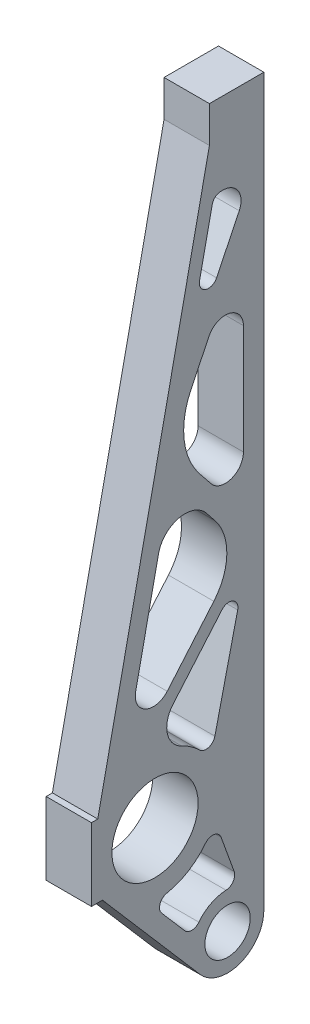
from build123d import *

# Parameters (mm, degrees)
SKETCH1_R                       = 15.08125
SKETCH1_R_2                     = 7.9375
BOSS_EXTRUDE1_DEPTH             = 7.9375
TAP_DRILL_FOR_1_4_28_TAP1_D     = 5.4102
TAP_DRILL_FOR_1_4_28_TAP1_DEPTH = 14.249611939
TAP_DRILL_FOR_1_4_28_TAP1_TIP   = 1.625388061


with BuildPart() as part:
    # Sketch1 → Boss-Extrude1 (new body, symmetric)
    with BuildSketch(Plane(origin=(0, 0, 0), x_dir=(0, 0, -1), z_dir=(1, 0, 0))):
        with BuildLine():
            ThreePointArc((477.273006468, 55.573710947), (477.957555138, 54.643144528), (478.689532564, 53.74940531))
            Line((478.689532564, 53.74940531), (511.29915841, 15.980017214))
            ThreePointArc((511.29915841, 15.980017214), (525.339576994, 12.376406632), (533.611992871, 24.279620434))
            Line((533.611992871, 24.279620434), (533.611992871, 252.869620434))
            ThreePointArc((533.611992871, 252.869620434), (533.621992871, 252.879620434), (533.611992871, 252.889620434))
            Line((533.611992871, 252.889620434), (533.611992871, 278.279620434))
            Line((533.611992871, 278.279620434), (514.561992871, 278.279620434))
            Line((514.561992871, 278.279620434), (514.561992871, 265.579620434))
            Line((514.561992871, 265.579620434), (475.482925659, 80.973710947))
            Line((475.482925659, 80.973710947), (473.286992871, 80.973710947))
            Line((473.286992871, 80.973710947), (473.286992871, 55.573710947))
            Line((473.286992871, 55.573710947), (477.273006468, 55.573710947))
        make_face()
        with Locations((495.511992871, 68.273710947)):
            Circle(SKETCH1_R, mode=Mode.SUBTRACT)
        with BuildLine():
            Line((513.492352541, 154.682917565), (516.491551882, 150.932886553))
            ThreePointArc((516.491551882, 150.932886553), (520.662032348, 138.733869971), (516.108721588, 126.672515404))
            Line((516.108721588, 126.672515404), (499.792202262, 107.541452006))
            ThreePointArc((499.792202262, 107.541452006), (492.156570852, 105.964813857), (488.748431965, 112.977177526))
            Line((488.748431965, 112.977177526), (496.735281949, 150.706320271))
            ThreePointArc((496.735281949, 150.706320271), (503.854492534, 158.001314948), (513.492352541, 154.682917565))
        make_face(mode=Mode.SUBTRACT)
        with BuildLine():
            Line((505.940679161, 31.90308853), (497.871284255, 41.249289229))
            ThreePointArc((497.871284255, 41.249289229), (497.275971755, 44.367979343), (499.679180371, 46.442880148))
            ThreePointArc((499.679180371, 46.442880148), (507.170500261, 49.352034741), (513.137493678, 54.73516057))
            ThreePointArc((513.137493678, 54.73516057), (516.142098705, 55.938560413), (518.64094789, 53.8814811))
            Line((518.64094789, 53.8814811), (523.222631148, 41.220667502))
            ThreePointArc((523.222631148, 41.220667502), (522.874411989, 38.372433477), (520.372083072, 36.968138764))
            ThreePointArc((520.372083072, 36.968138764), (515.06938347, 35.555874927), (510.857508795, 32.038315555))
            ThreePointArc((510.857508795, 32.038315555), (508.431176446, 30.804189453), (505.940679161, 31.90308853))
        make_face(mode=Mode.SUBTRACT)
        with Locations((520.911992871, 24.279620434)):
            Circle(SKETCH1_R_2, mode=Mode.SUBTRACT)
        with BuildLine():
            ThreePointArc((518.944357913, 122.658172896), (522.790818804, 123.432213046), (524.452355406, 119.877822007))
            Line((524.452355406, 119.877822007), (516.472291206, 85.606211423))
            ThreePointArc((516.472291206, 85.606211423), (514.260132633, 83.275664888), (511.146510795, 84.069674807))
            ThreePointArc((511.146510795, 84.069674807), (508.195718311, 86.524018724), (504.866661886, 88.434087744))
            ThreePointArc((504.866661886, 88.434087744), (499.826228678, 94.721972649), (501.785115668, 102.539019742))
            Line((501.785115668, 102.539019742), (518.944357913, 122.658172896))
        make_face(mode=Mode.SUBTRACT)
        with BuildLine():
            ThreePointArc((526.468242871, 166.731606566), (522.219734771, 160.739425678), (515.159193487, 162.76545866))
            Line((515.159193487, 162.76545866), (511.105468766, 167.834009193))
            ThreePointArc((511.105468766, 167.834009193), (505.69956043, 180.870864765), (508.086772693, 194.780741319))
            Line((508.086772693, 194.780741319), (514.404519469, 207.809941801))
            ThreePointArc((514.404519469, 207.809941801), (521.5395726, 211.228293635), (526.468242871, 205.039406675))
            Line((526.468242871, 205.039406675), (526.468242871, 166.731606566))
        make_face(mode=Mode.SUBTRACT)
        with BuildLine():
            ThreePointArc((515.536548916, 247.187161956), (516.643598283, 248.996229375), (518.642714422, 249.704620434))
            Line((518.642714422, 249.704620434), (519.289846204, 249.704620434))
            ThreePointArc((519.289846204, 249.704620434), (524.671082031, 246.725792482), (525.003569607, 240.584085308))
            Line((525.003569607, 240.584085308), (517.071165151, 224.224947846))
            ThreePointArc((517.071165151, 224.224947846), (513.18532078, 222.606581), (511.108137945, 226.26775693))
            Line((511.108137945, 226.26775693), (515.536548916, 247.187161956))
        make_face(mode=Mode.SUBTRACT)
    extrude(amount=BOSS_EXTRUDE1_DEPTH, both=True)

    # Tap Drill for 1/4-28 Tap1
    with Locations(Plane(origin=(0, 271.929620434, -533.611992871), x_dir=(-1, 0, 0), z_dir=(0, 0, -1))):
        with Locations((0, 0), (0, -12.7)):
            Hole(TAP_DRILL_FOR_1_4_28_TAP1_D / 2, depth=TAP_DRILL_FOR_1_4_28_TAP1_DEPTH)
            with Locations((0, 0, -(TAP_DRILL_FOR_1_4_28_TAP1_DEPTH + TAP_DRILL_FOR_1_4_28_TAP1_TIP / 2))):  # 118° drill point
                Cone(0, TAP_DRILL_FOR_1_4_28_TAP1_D / 2, TAP_DRILL_FOR_1_4_28_TAP1_TIP, mode=Mode.SUBTRACT)


solid = part.part
